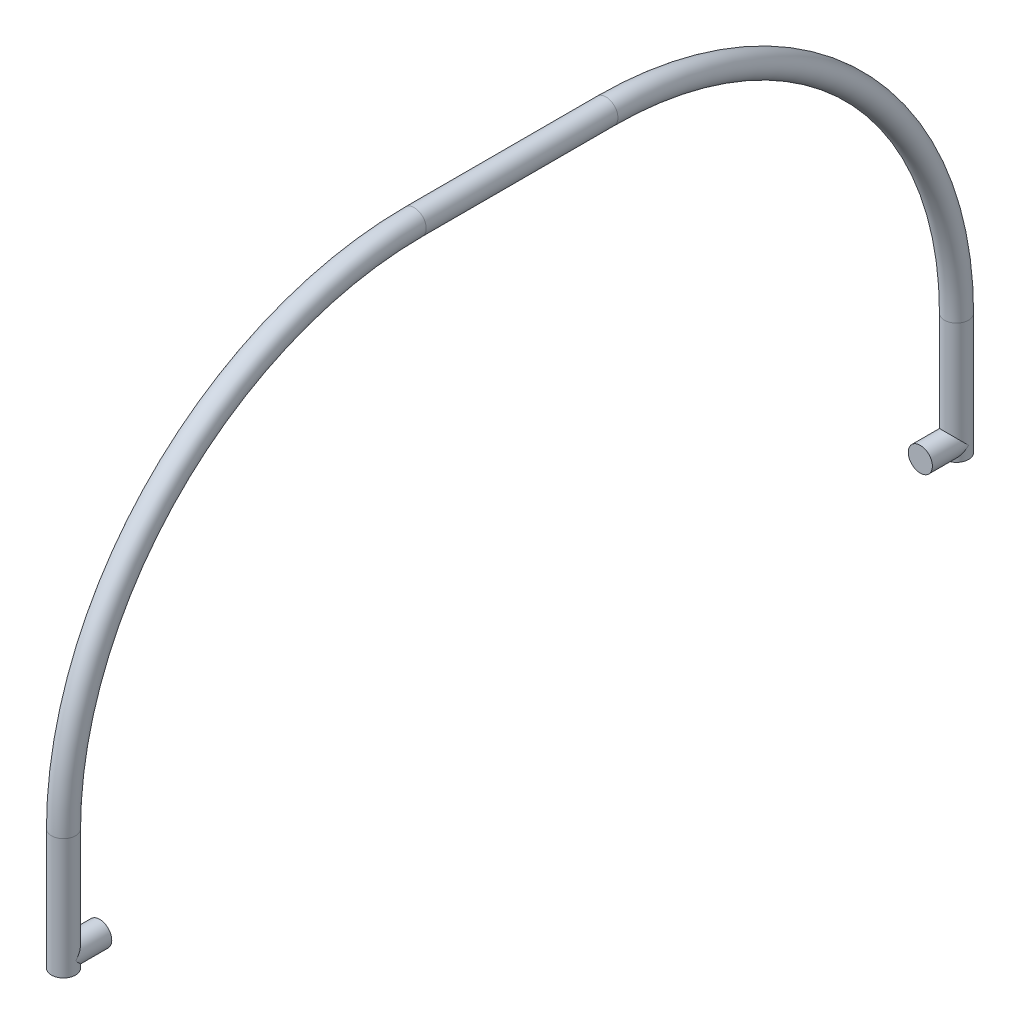
from build123d import *

# Parameters (mm, degrees)
SKETCH2_R                       = 5
SKETCH3_R                       = 5
BOSS_EXTRUDE1_DEPTH             = 10
BOSS_EXTRUDE1_DIRECTION_2_REACH = 12
BOSS_EXTRUDE2_START             = -5
SKETCH4_R                       = 5
BOSS_EXTRUDE2_DEPTH             = 15


with BuildPart() as part:
    # Sweep2: sweep along a path in Sketch1
    with BuildLine(Plane(origin=(0, 0, 0), x_dir=(0, 0, -1), z_dir=(1, 0, 0))) as sweep2_path:
        Line((-185, 0), (-185, 50))
        ThreePointArc((-185, 50), (-142.448359859, 152.728746731), (-39.719613128, 195.280386872))
        Line((-39.719613128, 195.280386872), (39.719613128, 195.280386872))
        ThreePointArc((39.719613128, 195.280386872), (142.448359859, 152.728746731), (185, 50))
        Line((185, 50), (185, 0))
    # Sketch2 → Sweep2 (sweep)
    with BuildSketch(Plane(origin=(0, 0, 0), x_dir=(1, 0, 0), z_dir=(0, 1, 0))):
        with Locations((0, 185)):
            Circle(SKETCH2_R)
    sweep(path=sweep2_path.line)


with BuildPart() as body_2:
    # Sketch3 → Boss-Extrude1 (new body)
    with BuildSketch(Plane.XY.offset(180)):
        with Locations((0, 5.031728254)):
            Circle(SKETCH3_R)
    extrude(amount=-BOSS_EXTRUDE1_DEPTH)


    # Sketch3 → Boss-Extrude1 direction 2 (add, up to next)
    with BuildSketch(Plane.XY.offset(180), mode=Mode.PRIVATE) as boss_extrude1_direction_2_sk1:
        with Locations((0, 5.031728254)):
            Circle(SKETCH3_R)
    boss_extrude1_direction_2_tool1 = extrude(boss_extrude1_direction_2_sk1.sketch, amount=BOSS_EXTRUDE1_DIRECTION_2_REACH, mode=Mode.PRIVATE) - part.part
    add(boss_extrude1_direction_2_tool1.solids().sort_by_distance((0, 5.031728, 180))[0])
    add(boss_extrude1_direction_2_tool1.solids().sort_by_distance((0, 5.031728, 180))[1])


with BuildPart() as part_1:
    add(part.part)

    # Sketch4 → Boss-Extrude2 (add)
    with BuildSketch(Plane.XY.offset(-180).offset(BOSS_EXTRUDE2_START)):
        with Locations((0, 5.110605583)):
            Circle(SKETCH4_R)
    extrude(amount=BOSS_EXTRUDE2_DEPTH)


solid = Compound([body_2.part, part_1.part])
